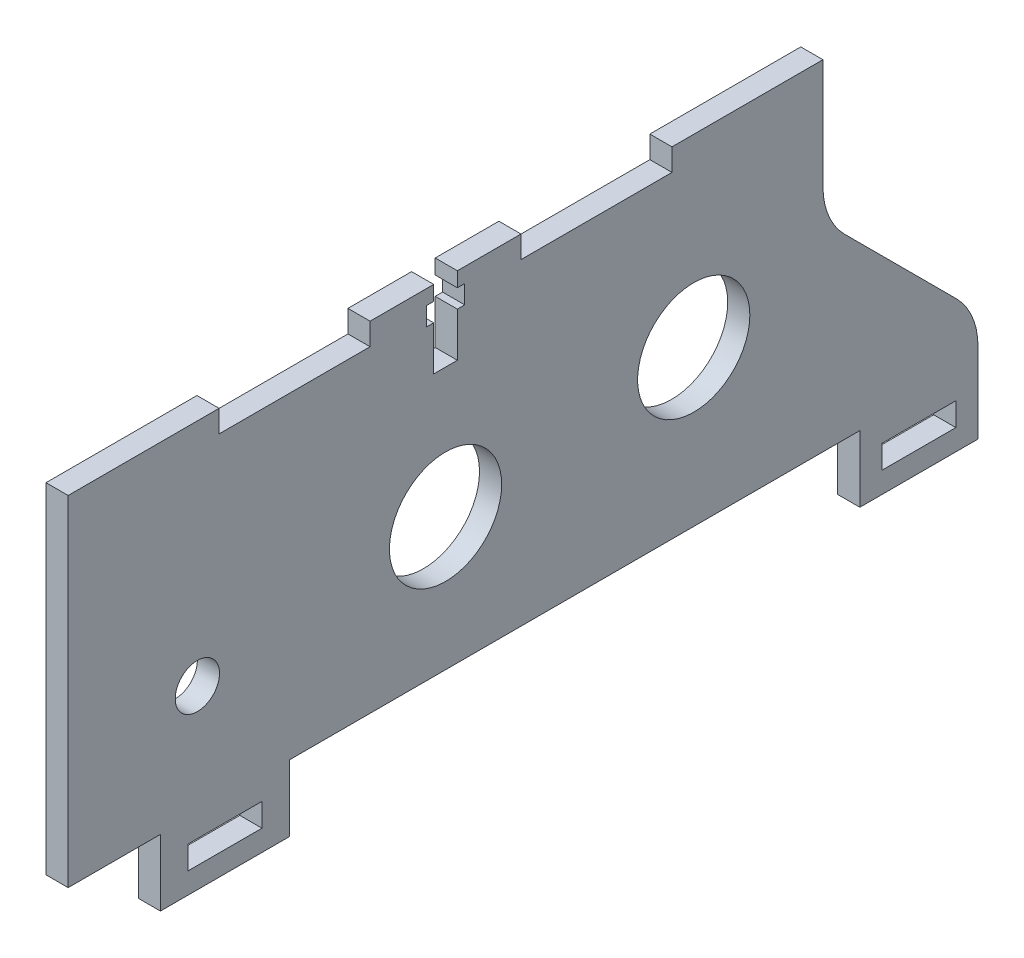
from build123d import *

# Parameters (mm, degrees)
SKETCH1_R               = 7.6
SKETCH1_R_2             = 3
SKETCH1_W               = 10
SKETCH1_H               = 3.15
BOSS_EXTRUDE1_DEPTH     = 3
FILLET1_R               = 10
SKETCH2_W               = 3.2
SKETCH2_H               = 6
SKETCH2_H_2             = 2.5
SKETCH2_W_2             = 1
SKETCH2_H_3             = 2
CUT_EXTRUDE1_DEPTH      = 1
CUT_EXTRUDE1_DEPTH_BACK = 4


with BuildPart() as part:
    # Sketch1 → Boss-Extrude1 (new body)
    with BuildSketch(Plane(origin=(0, 0, 0), x_dir=(0, 0, -1), z_dir=(1, 0, 0))):
        Polygon((102.223805307, 6), (123.223805307, 6), (102.223805307, 27), align=None)
        Polygon((102.223805307, 6), (123.223805307, 6), (123.223805307, -9), (107.223805307, -9), (107.223805307, 0), (30, 0), (30, -9), (12.5, -9), (12.5, 0), (0, 0), (0, 46), (20.444761061, 46), (20.444761061, 43), (40.889522123, 43), (40.889522123, 46), (61.334283184, 46), (61.334283184, 43), (81.779044246, 43), (81.779044246, 46), (102.223805307, 46), align=None)
        with Locations((84.723805307, 21)):
            Circle(SKETCH1_R, mode=Mode.SUBTRACT)
        with Locations((51.111902654, 17.95)):
            Circle(SKETCH1_R, mode=Mode.SUBTRACT)
        with Locations((17.5, 14.9)):
            Circle(SKETCH1_R_2, mode=Mode.SUBTRACT)
        with Locations((115.223805307, -4.575)):
            Rectangle(SKETCH1_W, SKETCH1_H, mode=Mode.SUBTRACT)
        with Locations((21.25, -4.575)):
            Rectangle(SKETCH1_W, SKETCH1_H, mode=Mode.SUBTRACT)
    extrude(amount=BOSS_EXTRUDE1_DEPTH)

    # Fillet1
    fillet1_edges = [part.edges().sort_by_distance(p)[0] for p in [
        (1.5, 6, -123.223805307),
        (1.5, 27, -102.223805307),
    ]]
    fillet(fillet1_edges, radius=FILLET1_R)

    # Sketch2 → Cut-Extrude1 (cut, two sides)
    with BuildSketch(Plane(origin=(3, 0, 0), x_dir=(0, 0, -1), z_dir=(1, 0, 0))) as cut_extrude1_sk:
        with Locations((51.111902654, 38.5)):
            Rectangle(SKETCH2_W, SKETCH2_H)
        with Locations((51.111902654, 42.75)):
            Rectangle(SKETCH2_W, SKETCH2_H_2)
        with Locations((49.011902654, 42.75)):
            Rectangle(SKETCH2_W_2, SKETCH2_H_2)
        with Locations((51.111902654, 45)):
            Rectangle(SKETCH2_W, SKETCH2_H_3)
        with Locations((53.211902654, 42.75)):
            Rectangle(SKETCH2_W_2, SKETCH2_H_2)
    extrude(amount=CUT_EXTRUDE1_DEPTH, mode=Mode.SUBTRACT)
    extrude(cut_extrude1_sk.sketch, amount=-CUT_EXTRUDE1_DEPTH_BACK, mode=Mode.SUBTRACT)


solid = part.part
